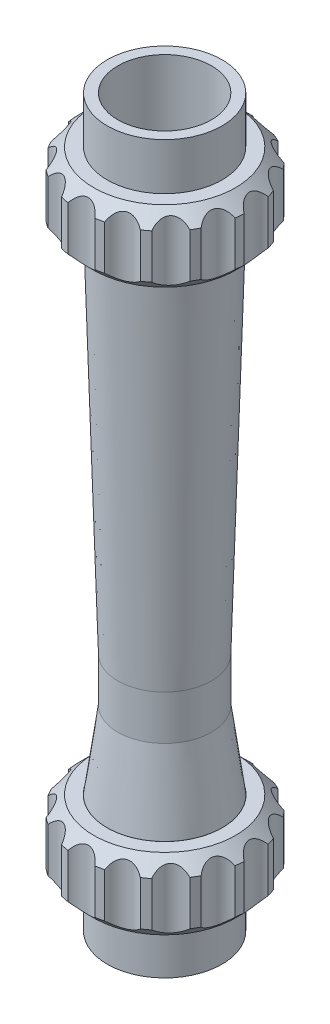
from build123d import *

# Parameters (mm, degrees)
SKETCH4_R          = 7.142857143
CUT_EXTRUDE1_DEPTH = 315.15282905
CIRPATTERN1_COUNT  = 15


with BuildPart() as part:
    # Rotameter → Revolve1 (revolve)
    with BuildSketch(Plane.XY):
        Polygon((-20, 310), (-24.5, 310), (-24.5, 290), (-30.25, 290), (-36, 284.25), (-36, 265.25), (-30.25, 259.5), (-24.6, 259.5), (-24.6, 273.85), (0, 273.85), (0, 279.5), (-20, 279.5), align=None)
        Polygon((-20, 0), (-20, 30.5), (0, 30.5), (0, 36.15), (-24.6, 36.15), (-24.6, 50.5), (-30.25, 50.5), (-36, 44.75), (-36, 25.75), (-30.25, 20), (-24.5, 20), (-24.5, 0), align=None)
        Polygon((-24.5, 259.5), (-20, 102.528186616), (-20, 83.528186616), (-24.5, 50.5), (-24.5, 36.25), (0, 36.25), (0, 273.75), (-24.5, 273.75), align=None)
    revolve(axis=Axis((0, 0, 0), (0, -1, 0)))

    # Sketch4 → Cut-Extrude1 (cut, through all)
    with BuildSketch(Plane.XZ):
        with Locations((0, 39.773809524)):
            Circle(SKETCH4_R)
    cut_extrude1 = extrude(amount=-CUT_EXTRUDE1_DEPTH, mode=Mode.SUBTRACT)

    # CirPattern1: Cut-Extrude1 ×15 about axis
    cirpattern1_axis = Axis((0, 0, 0), (0, 1, 0))
    for i in range(1, CIRPATTERN1_COUNT):
        add(cut_extrude1.rotate(cirpattern1_axis, i * 360 / CIRPATTERN1_COUNT), mode=Mode.SUBTRACT)


solid = part.part
